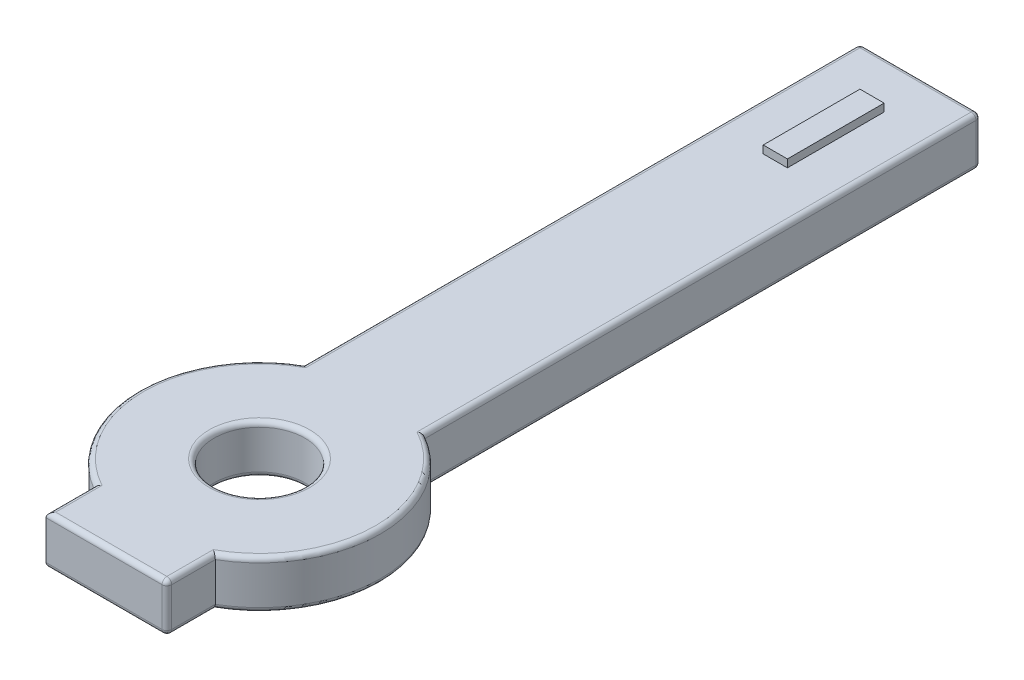
from build123d import *

# Parameters (mm, degrees)
SKETCH_1_R      = 1.875
EXTRUDE_1_DEPTH = 2
FILLET_1_R      = 0.2
SKETCH_2_W      = 1
SKETCH_2_H      = 4
EXTRUDE_2_DEPTH = 0.32


with BuildPart() as part:
    # 草图1 → 凸台-拉伸1 (new body)
    with BuildSketch(Plane(origin=(0, 0, 0), x_dir=(1, 0, 0), z_dir=(0, 1, 0))):
        with BuildLine():
            Line((2.5, 27.330127019), (-2.5, 27.330127019))
            Line((-2.5, 27.330127019), (-2.5, 4.330127019))
            ThreePointArc((-2.5, 4.330127019), (-5, 0), (-2.5, -4.330127019))
            Line((-2.5, -4.330127019), (-2.5, -6.330127019))
            Line((-2.5, -6.330127019), (2.5, -6.330127019))
            Line((2.5, -6.330127019), (2.5, -4.330127019))
            ThreePointArc((2.5, -4.330127019), (5, 0), (2.5, 4.330127019))
            Line((2.5, 4.330127019), (2.5, 27.330127019))
        make_face()
        Circle(SKETCH_1_R, mode=Mode.SUBTRACT)
    extrude(amount=EXTRUDE_1_DEPTH)

    # 圆角1
    fillet_1_edges = [part.edges().sort_by_distance(p)[0] for p in [
        (-1.875, 0, 0),
        (2.5, 2, -15.830127019),
        (2.5, 0, 5.330127019),
        (0, 0, 6.330127019),
        (-2.5, 0, 5.330127019),
        (-5, 0, 0),
        (-2.5, 0, -15.830127019),
        (0, 0, -27.330127019),
        (2.5, 0, -15.830127019),
        (5, 0, 0),
        (0, 2, -27.330127019),
        (2.5, 1, 6.330127019),
        (-2.5, 1, -27.330127019),
        (2.5, 1, -27.330127019),
        (-2.5, 2, -15.830127019),
        (-5, 2, 0),
        (-2.5, 2, 5.330127019),
        (0, 2, 6.330127019),
        (2.5, 2, 5.330127019),
        (-1.875, 2, 0),
        (5, 2, 0),
    ]]
    fillet(fillet_1_edges, radius=FILLET_1_R)

    # 草图2 → 凸台-拉伸2 (add)
    with BuildSketch(Plane(origin=(0, 2, 0), x_dir=(1, 0, 0), z_dir=(0, 1, 0))):
        with Locations((0, 23.330127019)):
            Rectangle(SKETCH_2_W, SKETCH_2_H)
    extrude(amount=EXTRUDE_2_DEPTH)


solid = part.part
